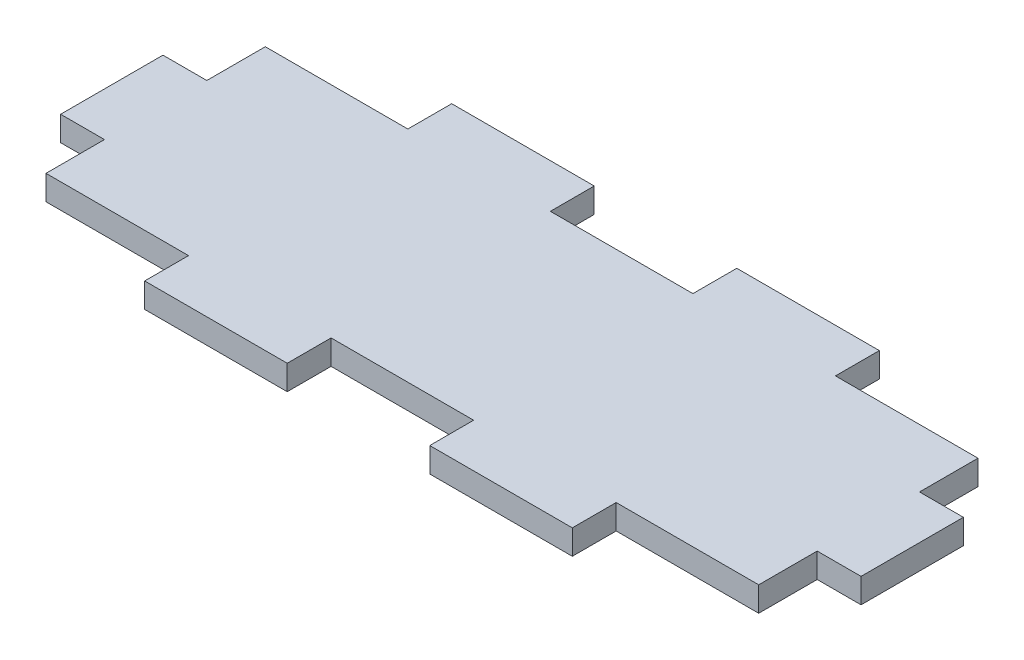
from build123d import *

# Parameters (mm, degrees)
SKETCH1_W           = 65
SKETCH1_H           = 20
SKETCH1_W_2         = 4
SKETCH1_H_2         = 9.333333334
SKETCH1_W_3         = 13
SKETCH1_H_3         = 4
BOSS_EXTRUDE1_DEPTH = 2.25


with BuildPart() as part:
    # Sketch1 → Boss-Extrude1 (new body)
    with BuildSketch(Plane(origin=(0, 0, 0), x_dir=(1, 0, 0), z_dir=(0, 1, 0))):
        with Locations((32.5, 10)):
            Rectangle(SKETCH1_W, SKETCH1_H)
        with Locations((-2, 10)):
            Rectangle(SKETCH1_W_2, SKETCH1_H_2)
        with Locations((19.5, -2)):
            Rectangle(SKETCH1_W_3, SKETCH1_H_3)
        with Locations((19.5, 22)):
            Rectangle(SKETCH1_W_3, SKETCH1_H_3)
        with Locations((45.5, 22)):
            Rectangle(SKETCH1_W_3, SKETCH1_H_3)
        with Locations((45.5, -2)):
            Rectangle(SKETCH1_W_3, SKETCH1_H_3)
        with Locations((67, 10)):
            Rectangle(SKETCH1_W_2, SKETCH1_H_2)
    extrude(amount=BOSS_EXTRUDE1_DEPTH)


solid = part.part
